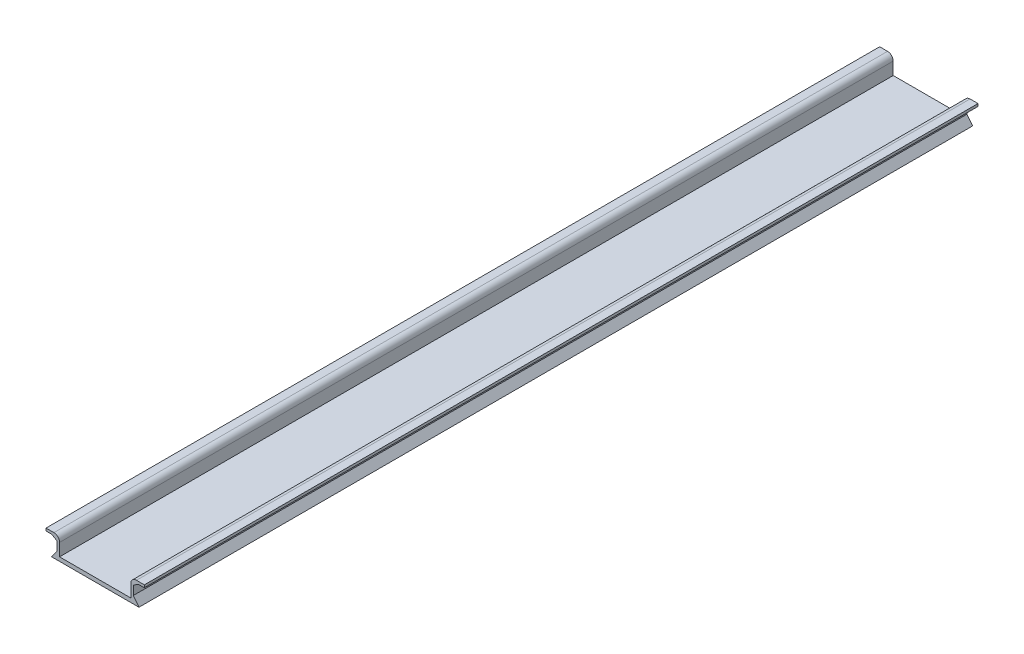
from build123d import *

# Parameters (mm, degrees)
BOSS_EXTRUDE1_DEPTH = 295


with BuildPart() as part:
    # Sketch1 → Boss-Extrude1 (new body)
    with BuildSketch(Plane.XY):
        with BuildLine():
            Line((-15.5, 0), (15.5, 0))
            Line((15.5, 0), (13.5, 2.6))
            Line((13.5, 2.6), (13.5, 5.8))
            Line((13.5, 5.8), (15.3, 6.92))
            Line((15.3, 6.92), (17.4, 6.92))
            Line((17.4, 6.92), (17.4, 7.82))
            Line((17.4, 7.82), (14.6, 7.82))
            ThreePointArc((14.6, 7.82), (13.185786438, 7.234213562), (12.6, 5.82))
            Line((12.6, 5.82), (12.6, 1.4))
            Line((12.6, 1.4), (-12.6, 1.4))
            Line((-12.6, 1.4), (-12.6, 5.82))
            ThreePointArc((-12.6, 5.82), (-13.185786438, 7.234213562), (-14.6, 7.82))
            Line((-14.6, 7.82), (-17.4, 7.82))
            Line((-17.4, 7.82), (-17.4, 6.92))
            Line((-17.4, 6.92), (-15.3, 6.92))
            Line((-15.3, 6.92), (-13.5, 5.8))
            Line((-13.5, 5.8), (-13.5, 2.6))
            Line((-13.5, 2.6), (-15.5, 0))
        make_face()
    extrude(amount=BOSS_EXTRUDE1_DEPTH)


solid = part.part
